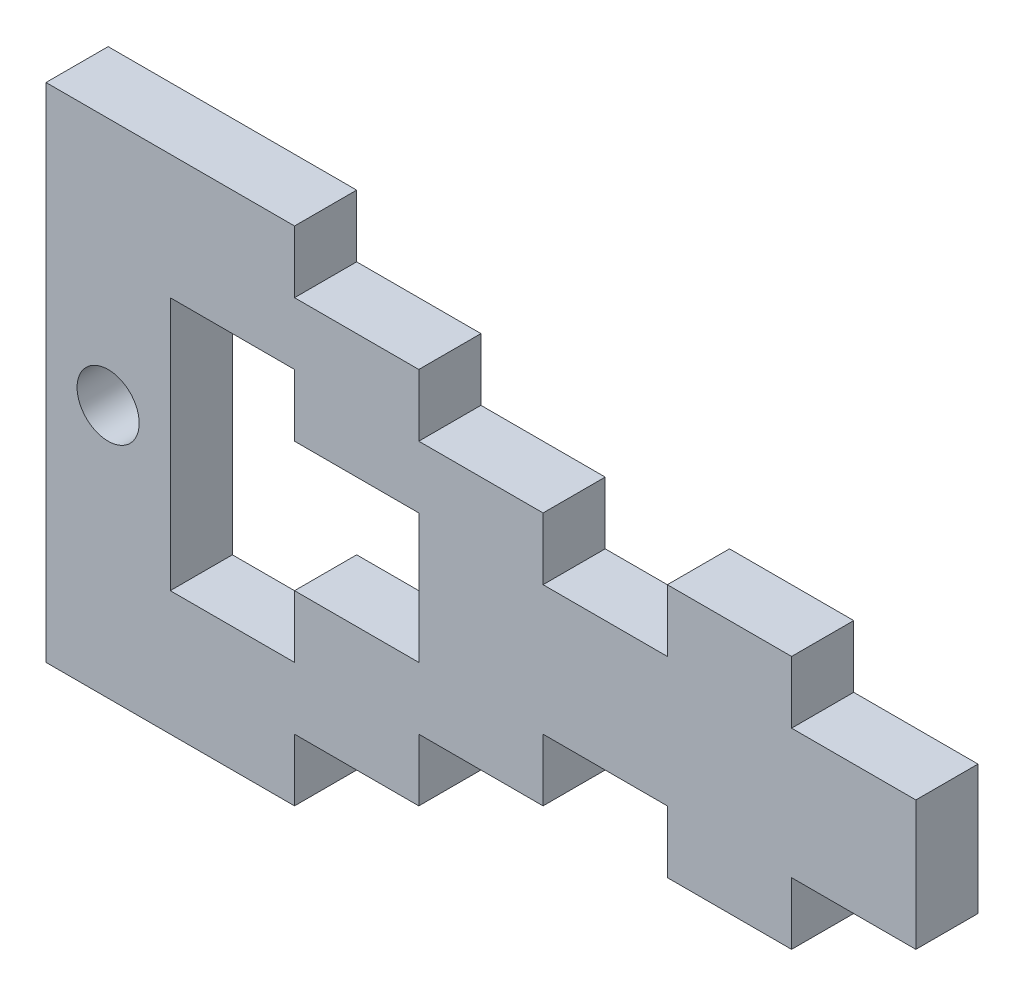
from build123d import *

# Parameters (mm, degrees)
MODEL_R             = 1.5
BOSS_EXTRUDE1_DEPTH = 3


with BuildPart() as part:
    # Model → Boss-Extrude1 (new body)
    with BuildSketch(Plane.XY):
        Polygon((3258.106732125, 1248.388404039), (3264.106732125, 1248.388404039), (3264.106732125, 1245.388404039), (3264.106732125, 1242.138404039), (3258.106732125, 1242.138404039), (3258.106732125, 1239.138404039), (3252.106732125, 1239.138404039), (3252.106732125, 1242.138404039), (3246.106732125, 1242.138404039), (3246.106732125, 1239.138404039), (3240.106732125, 1239.138404039), (3240.106732125, 1236.138404039), (3234.106732125, 1236.138404039), (3234.106732125, 1233.138404039), (3228.106732125, 1233.138404039), (3222.106732125, 1233.138404039), (3222.106732125, 1245.388404039), (3222.106732125, 1257.388404039), (3228.106732125, 1257.388404039), (3234.106732125, 1257.388404039), (3234.106732125, 1254.388404039), (3240.106732125, 1254.388404039), (3240.106732125, 1251.388404039), (3246.106732125, 1251.388404039), (3246.106732125, 1248.388404039), (3252.106732125, 1248.388404039), (3252.106732125, 1251.388404039), (3258.106732125, 1251.388404039), align=None)
        with Locations((3225.106732125, 1245.388404039)):
            Circle(MODEL_R, mode=Mode.SUBTRACT)
        Polygon((3240.106732125, 1248.388404039), (3234.106732125, 1248.388404039), (3234.106732125, 1251.388404039), (3228.106732125, 1251.388404039), (3228.106732125, 1245.388404039), (3228.106732125, 1239.138404039), (3234.106732125, 1239.138404039), (3234.106732125, 1242.138404039), (3240.106732125, 1242.138404039), align=None, mode=Mode.SUBTRACT)
    extrude(amount=BOSS_EXTRUDE1_DEPTH)


solid = part.part
